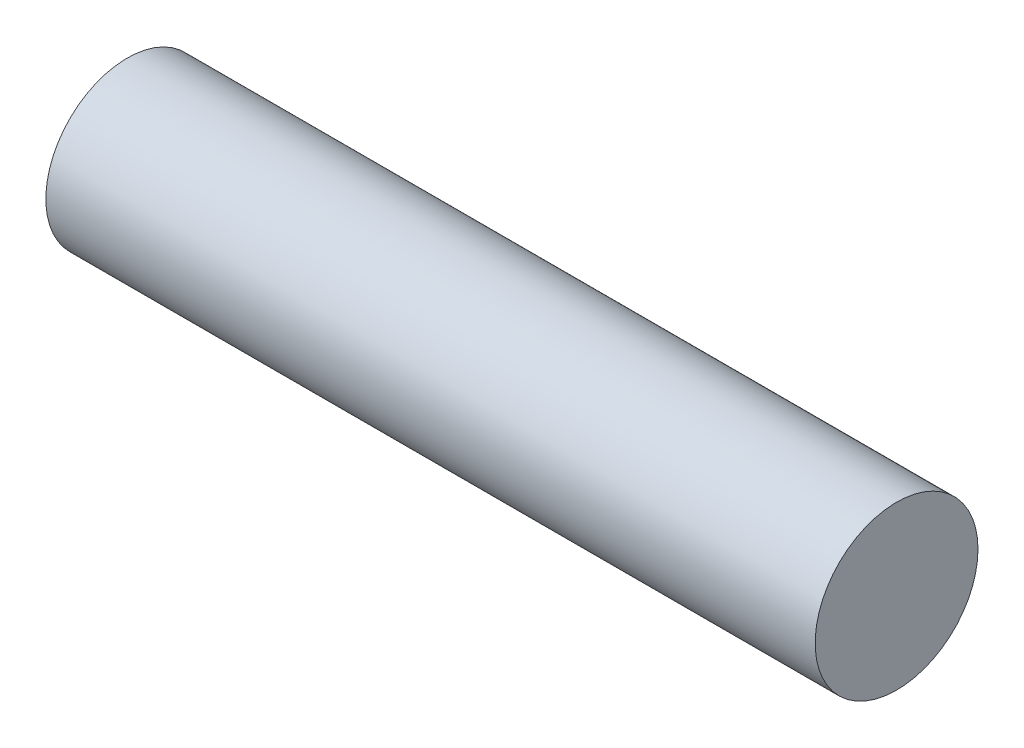
from build123d import *

# Parameters (mm, degrees)
BALAYAGE1_PROFILE_R = 3.175


with BuildPart() as part:
    # Balayage1: sweep along a path in Esquisse1
    with BuildLine(Plane.XY) as balayage1_path:
        Line((-30.901990077, 0), (-0.901990077, 0))
    # Balayage1 profile (on start of the path) → Balayage1 (sweep)
    with BuildSketch(Plane(origin=(-30.901990077, 0, 0), x_dir=(0, 0, 1), z_dir=(1, 0, 0))):
        Circle(BALAYAGE1_PROFILE_R)
    sweep(path=balayage1_path.line)


solid = part.part
